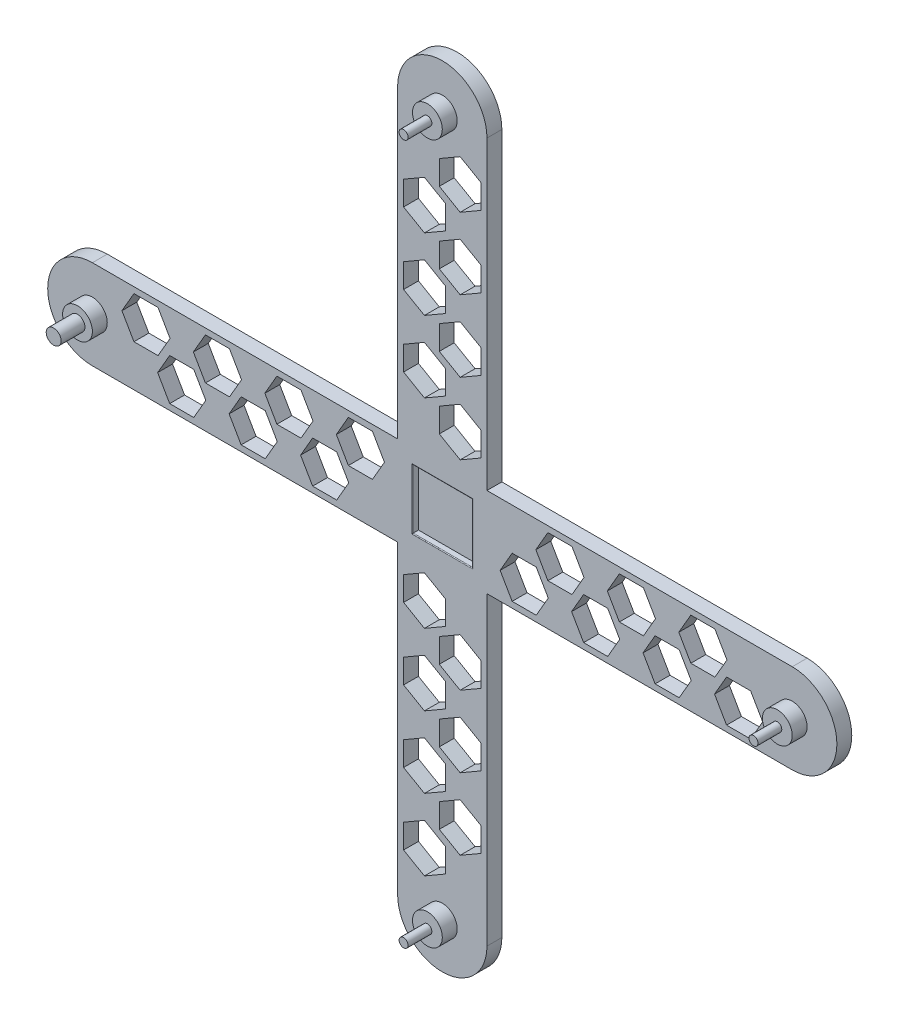
from build123d import *

# Parameters (mm, degrees)
BOSS_EXTRUDE1_DEPTH = 5
SKETCH5_R           = 5
BOSS_EXTRUDE2_DEPTH = 5
SKETCH7_R           = 1.5
SKETCH7_R_2         = 2.5
BOSS_EXTRUDE3_DEPTH = 8
CUT_EXTRUDE1_DEPTH  = 8
SKETCH11_W          = 20
SKETCH11_H          = 20
CUT_EXTRUDE3_DEPTH  = 2
FILLET8_R           = 0.25


with BuildPart() as part:
    # Sketch1 → Boss-Extrude1 (new body)
    with BuildSketch(Plane.XY):
        with BuildLine():
            Line((15, 15), (117.5, 15))
            ThreePointArc((117.5, 15), (132.5, 0), (117.5, -15))
            Line((117.5, -15), (15, -15))
            Line((15, -15), (15, -117.5))
            ThreePointArc((15, -117.5), (0, -132.5), (-15, -117.5))
            Line((-15, -117.5), (-15, -15))
            Line((-15, -15), (-117.5, -15))
            ThreePointArc((-117.5, -15), (-132.5, 0), (-117.5, 15))
            Line((-117.5, 15), (-15, 15))
            Line((-15, 15), (-15, 117.5))
            ThreePointArc((-15, 117.5), (0, 132.5), (15, 117.5))
            Line((15, 117.5), (15, 15))
        make_face()
    extrude(amount=BOSS_EXTRUDE1_DEPTH)

    # Sketch5 → Boss-Extrude2 (add)
    with BuildSketch(Plane.XY.offset(5)):
        with Locations((-117.5, 0)):
            Circle(SKETCH5_R)
        with Locations((0, -117.5)):
            Circle(SKETCH5_R)
        with Locations((117.5, 0)):
            Circle(SKETCH5_R)
        with Locations((0, 117.5)):
            Circle(SKETCH5_R)
    extrude(amount=BOSS_EXTRUDE2_DEPTH)

    # Sketch7 → Boss-Extrude3 (add)
    with BuildSketch(Plane.XY.offset(10)):
        with Locations((117.5, 0)):
            Circle(SKETCH7_R)
        with Locations((0, -117.5)):
            Circle(SKETCH7_R)
        with Locations((-117.5, 0)):
            Circle(SKETCH7_R_2)
        with Locations((0, 117.5)):
            Circle(SKETCH7_R)
    extrude(amount=BOSS_EXTRUDE3_DEPTH)

    # Sketch8 → Cut-Extrude1 (cut)
    with BuildSketch(Plane.XY.offset(5)):
        Polygon((6, 91.417096231), (13, 95.458548116), (13, 103.541451884), (6, 107.582903769), (-1, 103.541451884), (-1, 95.458548116), align=None)
        Polygon((-91.417096231, 6), (-95.458548116, 13), (-103.541451884, 13), (-107.582903769, 6), (-103.541451884, -1), (-95.458548116, -1), align=None)
        Polygon((-79.417096231, -6), (-83.458548116, 1), (-91.541451884, 1), (-95.582903769, -6), (-91.541451884, -13), (-83.458548116, -13), align=None)
        Polygon((-55.417096231, -6), (-59.458548116, 1), (-67.541451884, 1), (-71.582903769, -6), (-67.541451884, -13), (-59.458548116, -13), align=None)
        Polygon((-43.417096231, 6), (-47.458548116, 13), (-55.541451884, 13), (-59.582903769, 6), (-55.541451884, -1), (-47.458548116, -1), align=None)
        Polygon((-19.417096231, 6), (-23.458548116, 13), (-31.541451884, 13), (-35.582903769, 6), (-31.541451884, -1), (-23.458548116, -1), align=None)
        Polygon((-31.417096231, -6), (-35.458548116, 1), (-43.541451884, 1), (-47.582903769, -6), (-43.541451884, -13), (-35.458548116, -13), align=None)
        Polygon((-67.417096231, 6), (-71.458548116, 13), (-79.541451884, 13), (-83.582903769, 6), (-79.541451884, -1), (-71.458548116, -1), align=None)
        Polygon((-6, 79.417096231), (1, 83.458548116), (1, 91.541451884), (-6, 95.582903769), (-13, 91.541451884), (-13, 83.458548116), align=None)
        Polygon((6, 67.417096231), (13, 71.458548116), (13, 79.541451884), (6, 83.582903769), (-1, 79.541451884), (-1, 71.458548116), align=None)
        Polygon((-6, 55.417096231), (1, 59.458548116), (1, 67.541451884), (-6, 71.582903769), (-13, 67.541451884), (-13, 59.458548116), align=None)
        Polygon((6, 43.417096231), (13, 47.458548116), (13, 55.541451884), (6, 59.582903769), (-1, 55.541451884), (-1, 47.458548116), align=None)
        Polygon((-6, 31.417096231), (1, 35.458548116), (1, 43.541451884), (-6, 47.582903769), (-13, 43.541451884), (-13, 35.458548116), align=None)
        Polygon((6, 19.417096231), (13, 23.458548116), (13, 31.541451884), (6, 35.582903769), (-1, 31.541451884), (-1, 23.458548116), align=None)
        Polygon((91.417096231, -6), (95.458548116, -13), (103.541451884, -13), (107.582903769, -6), (103.541451884, 1), (95.458548116, 1), align=None)
        Polygon((79.417096231, 6), (83.458548116, -1), (91.541451884, -1), (95.582903769, 6), (91.541451884, 13), (83.458548116, 13), align=None)
        Polygon((67.417096231, -6), (71.458548116, -13), (79.541451884, -13), (83.582903769, -6), (79.541451884, 1), (71.458548116, 1), align=None)
        Polygon((55.417096231, 6), (59.458548116, -1), (67.541451884, -1), (71.582903769, 6), (67.541451884, 13), (59.458548116, 13), align=None)
        Polygon((43.417096231, -6), (47.458548116, -13), (55.541451884, -13), (59.582903769, -6), (55.541451884, 1), (47.458548116, 1), align=None)
        Polygon((31.417096231, 6), (35.458548116, -1), (43.541451884, -1), (47.582903769, 6), (43.541451884, 13), (35.458548116, 13), align=None)
        Polygon((19.417096231, -6), (23.458548116, -13), (31.541451884, -13), (35.582903769, -6), (31.541451884, 1), (23.458548116, 1), align=None)
        Polygon((-6, -91.417096231), (-13, -95.458548116), (-13, -103.541451884), (-6, -107.582903769), (1, -103.541451884), (1, -95.458548116), align=None)
        Polygon((6, -79.417096231), (-1, -83.458548116), (-1, -91.541451884), (6, -95.582903769), (13, -91.541451884), (13, -83.458548116), align=None)
        Polygon((-6, -67.417096231), (-13, -71.458548116), (-13, -79.541451884), (-6, -83.582903769), (1, -79.541451884), (1, -71.458548116), align=None)
        Polygon((6, -55.417096231), (-1, -59.458548116), (-1, -67.541451884), (6, -71.582903769), (13, -67.541451884), (13, -59.458548116), align=None)
        Polygon((-6, -43.417096231), (-13, -47.458548116), (-13, -55.541451884), (-6, -59.582903769), (1, -55.541451884), (1, -47.458548116), align=None)
        Polygon((6, -31.417096231), (-1, -35.458548116), (-1, -43.541451884), (6, -47.582903769), (13, -43.541451884), (13, -35.458548116), align=None)
        Polygon((-6, -19.417096231), (-13, -23.458548116), (-13, -31.541451884), (-6, -35.582903769), (1, -31.541451884), (1, -23.458548116), align=None)
    extrude(amount=-CUT_EXTRUDE1_DEPTH, mode=Mode.SUBTRACT)

    # Sketch11 → Cut-Extrude3 (cut)
    with BuildSketch(Plane.XY.offset(5)):
        Rectangle(SKETCH11_W, SKETCH11_H)
    extrude(amount=-CUT_EXTRUDE3_DEPTH, mode=Mode.SUBTRACT)

    # Fillet8
    fillet8_edges = [part.edges().sort_by_distance(p)[0] for p in [
        (10, 0, 5),
        (0, 10, 5),
        (-10, 0, 5),
        (0, -10, 5),
    ]]
    fillet(fillet8_edges, radius=FILLET8_R)


solid = part.part
